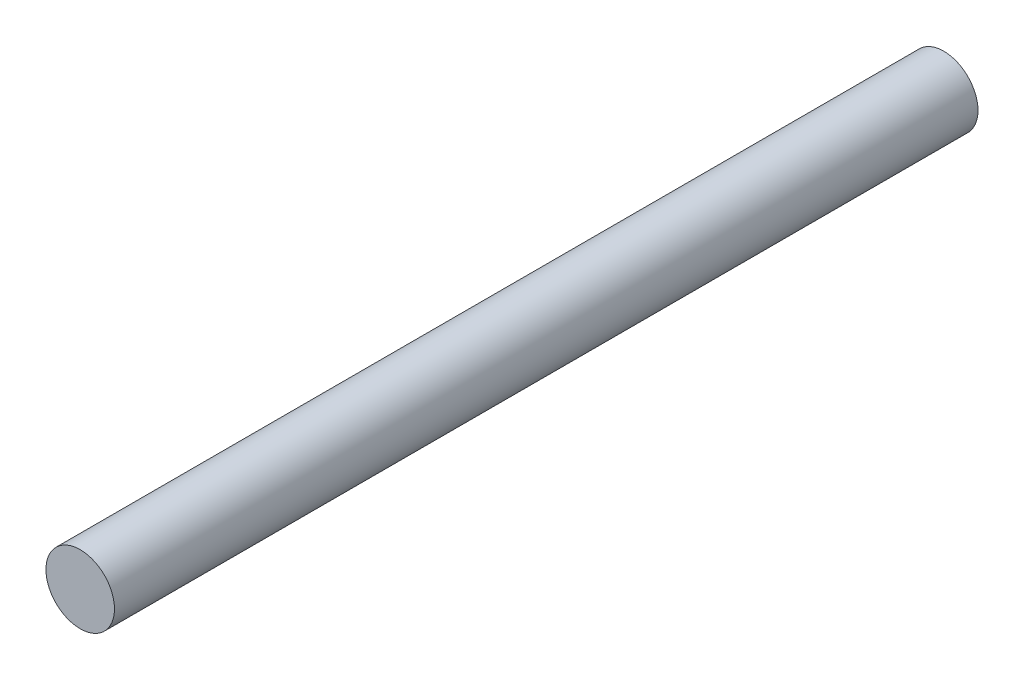
from build123d import *

# Parameters (mm, degrees)
SKETCH1_R           = 4.7625
BOSS_EXTRUDE1_DEPTH = 120


with BuildPart() as part:
    # Sketch1 → Boss-Extrude1 (new body)
    with BuildSketch(Plane.XY):
        Circle(SKETCH1_R)
    extrude(amount=BOSS_EXTRUDE1_DEPTH)


solid = part.part
